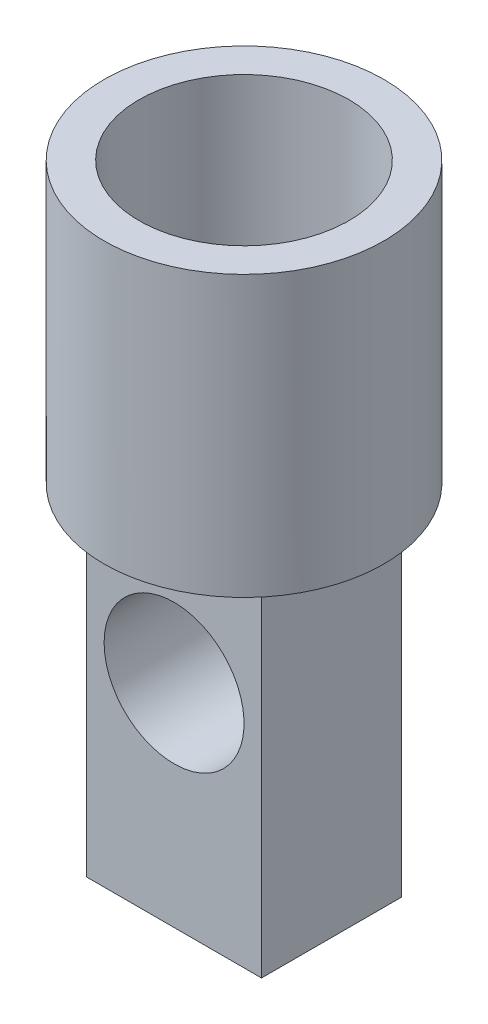
from build123d import *

# Parameters (mm, degrees)
SKETCH1_W               = 0.5
SKETCH1_H               = 3
SKETCH2_R               = 2
BOSS_EXTRUDE1_DEPTH     = 1
SKETCH3_W               = 2.5
SKETCH3_H               = 2
BOSS_EXTRUDE2_DEPTH     = 5
SKETCH4_R               = 1
CUT_EXTRUDE1_DEPTH      = 3
CUT_EXTRUDE1_DEPTH_BACK = 3


with BuildPart() as part:
    # Sketch1 → Revolve1 (revolve)
    with BuildSketch(Plane.XY):
        with Locations((-1.75, 1.5)):
            Rectangle(SKETCH1_W, SKETCH1_H)
    revolve(axis=Axis((0, 0, 0), (0, 1, 0)))

    # Sketch2 → Boss-Extrude1 (add)
    with BuildSketch(Plane(origin=(0, 0, 0), x_dir=(1, 0, 0), z_dir=(0, 1, 0))):
        Circle(SKETCH2_R)
    extrude(amount=-BOSS_EXTRUDE1_DEPTH)

    # Sketch3 → Boss-Extrude2 (add)
    with BuildSketch(Plane.XZ.offset(1)):
        Rectangle(SKETCH3_W, SKETCH3_H)
    extrude(amount=BOSS_EXTRUDE2_DEPTH)

    # Sketch4 → Cut-Extrude1 (cut, two sides)
    with BuildSketch(Plane(origin=(0, 0, 0), x_dir=(-1, 0, 0), z_dir=(0, 0, -1))) as cut_extrude1_sk:
        with Locations((0, -2.973084611)):
            Circle(SKETCH4_R)
    extrude(amount=CUT_EXTRUDE1_DEPTH, mode=Mode.SUBTRACT)
    extrude(cut_extrude1_sk.sketch, amount=-CUT_EXTRUDE1_DEPTH_BACK, mode=Mode.SUBTRACT)


solid = part.part
